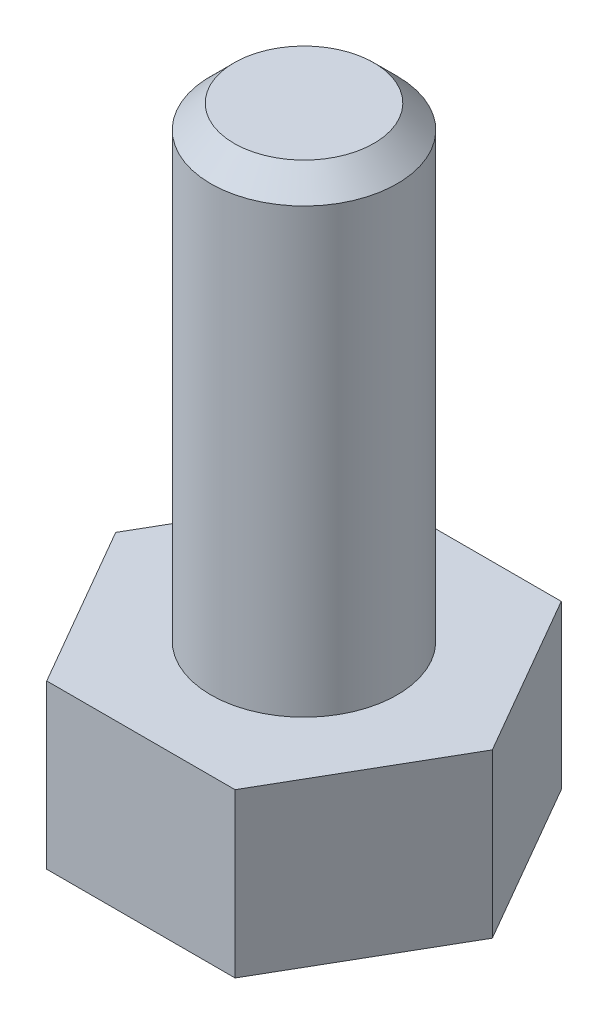
from build123d import *

# Parameters (mm, degrees)
SKETCH1_R           = 2
BOSS_EXTRUDE1_DEPTH = 3.5
BOSS_EXTRUDE2_START = 3.5
SKETCH1_3_R         = 2
BOSS_EXTRUDE2_DEPTH = 10
CHAMFER1_SIZE       = 0.5


with BuildPart() as part:
    # Sketch1 → Boss-Extrude1 (new body)
    with BuildSketch(Plane(origin=(0, 0, 0), x_dir=(1, 0, 0), z_dir=(0, 1, 0))):
        Polygon((-4.041451884, 0), (-2.020725942, -3.5), (2.020725942, -3.5), (4.041451884, 0), (2.020725942, 3.5), (-2.020725942, 3.5), align=None)
        Circle(SKETCH1_R, mode=Mode.SUBTRACT)
        Circle(SKETCH1_R)
    extrude(amount=BOSS_EXTRUDE1_DEPTH)

    # Sketch1_3 → Boss-Extrude2 (add)
    with BuildSketch(Plane(origin=(0, 0, 0), x_dir=(1, 0, 0), z_dir=(0, 1, 0)).offset(BOSS_EXTRUDE2_START)):
        with Locations(Location((0, 0, 0), (0, 0, 270))):
            Circle(SKETCH1_3_R)
    extrude(amount=BOSS_EXTRUDE2_DEPTH)

    # Chamfer1
    chamfer1_edges = [part.edges().sort_by_distance(p)[0] for p in [
        (0, 13.5, -2),
    ]]
    chamfer(chamfer1_edges, length=CHAMFER1_SIZE)


solid = part.part
